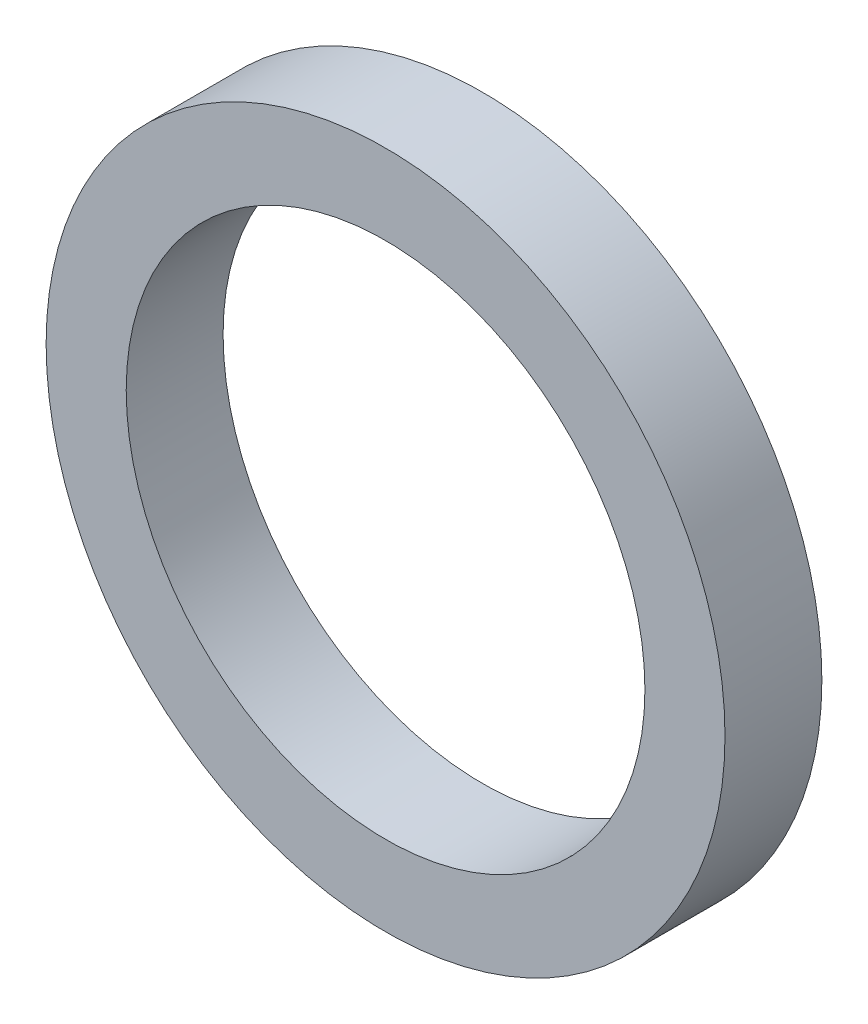
from build123d import *

# Parameters (mm, degrees)
SKETCH1_R           = 133.5
SKETCH1_R_2         = 102
BOSS_EXTRUDE1_DEPTH = 38.1


with BuildPart() as part:
    # Sketch1 → Boss-Extrude1 (new body)
    with BuildSketch(Plane.XY):
        Circle(SKETCH1_R)
        Circle(SKETCH1_R_2, mode=Mode.SUBTRACT)
    extrude(amount=BOSS_EXTRUDE1_DEPTH)


solid = part.part
